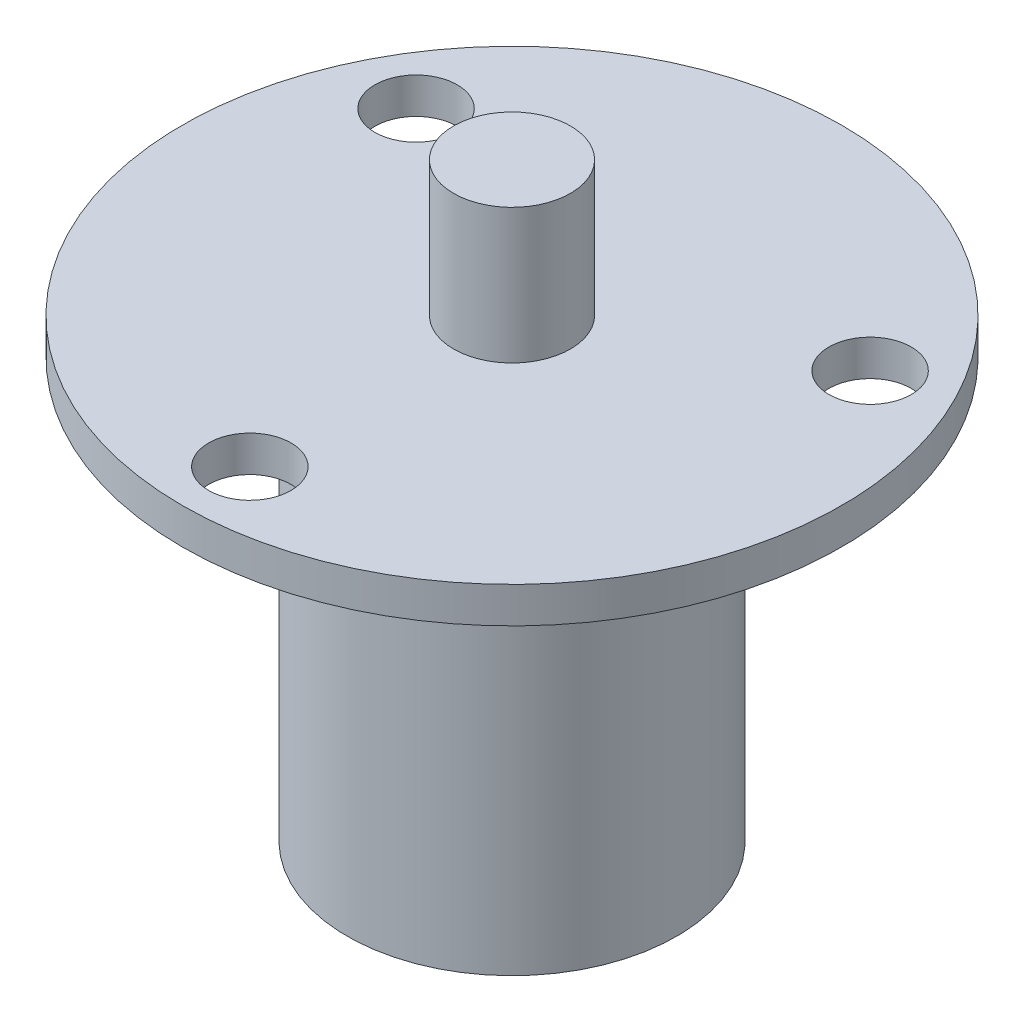
from build123d import *

# Parameters (mm, degrees)
SKETCH2_R           = 22
SKETCH2_R_2         = 2.75
BOSS_EXTRUDE1_DEPTH = 2.4
SKETCH3_R           = 3.9
BOSS_EXTRUDE2_DEPTH = 9
SKETCH4_R           = 11
BOSS_EXTRUDE3_DEPTH = 28


with BuildPart() as part:
    # Sketch2 → Boss-Extrude1 (new body)
    with BuildSketch(Plane(origin=(0, 0, 0), x_dir=(1, 0, 0), z_dir=(0, 1, 0))):
        Circle(SKETCH2_R)
        with Locations((15.155444566, 8.75)):
            Circle(SKETCH2_R_2, mode=Mode.SUBTRACT)
        with Locations((-15.155444566, 8.75)):
            Circle(SKETCH2_R_2, mode=Mode.SUBTRACT)
        with Locations((0, -17.5)):
            Circle(SKETCH2_R_2, mode=Mode.SUBTRACT)
    extrude(amount=BOSS_EXTRUDE1_DEPTH)

    # Sketch3 → Boss-Extrude2 (add)
    with BuildSketch(Plane(origin=(0, 2.4, 0), x_dir=(1, 0, 0), z_dir=(0, 1, 0))):
        Circle(SKETCH3_R)
    extrude(amount=BOSS_EXTRUDE2_DEPTH)

    # Sketch4 → Boss-Extrude3 (add)
    with BuildSketch(Plane.XZ):
        Circle(SKETCH4_R)
    extrude(amount=BOSS_EXTRUDE3_DEPTH)


solid = part.part
